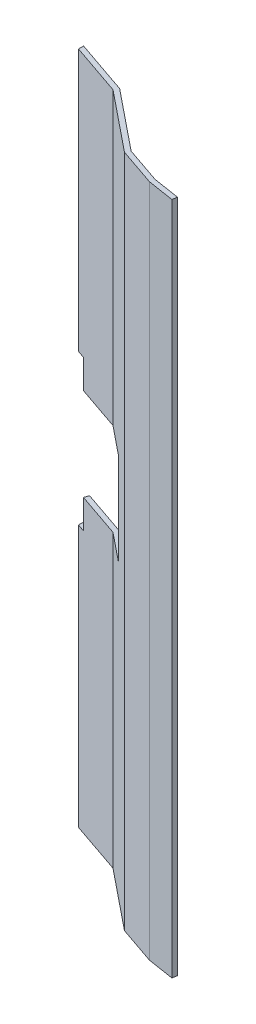
from build123d import *

# Parameters (mm, degrees)
BOSS_EXTRUDE2_DEPTH     = 222.25
SKETCH4_W               = 3.175
SKETCH4_H               = 9.525
SKETCH4_W_2             = 11.35728502
SKETCH4_H_2             = 30.48
CUT_EXTRUDE2_DEPTH      = 20.034637206
CUT_EXTRUDE2_DEPTH_BACK = 28.684375793


with BuildPart() as part:
    # Sketch3 → Boss-Extrude2 (new body)
    with BuildSketch(Plane(origin=(0, 0, 0), x_dir=(1, 0, 0), z_dir=(0, 1, 0))):
        Polygon((-37.062566366, 21.904788086), (-19.755538483, 15.964920897), (0, 0), (12.541749156, -4.304397313), (21.323689681, -5.686287551), (21.57426256, -4.093891817), (12.792322036, -2.712001578), (0.780092903, 1.410661549), (-18.975445581, 17.375582446), (-37.062566366, 23.583181811), align=None)
    extrude(amount=BOSS_EXTRUDE2_DEPTH)

    # Sketch4 → Cut-Extrude2 (cut, two sides)
    with BuildSketch(Plane(origin=(3.335400558, 0, -9.718377301), x_dir=(-0.945844814, 0, -0.324619144), z_dir=(0.324619144, 0, -0.945844814))) as cut_extrude2_sk:
        with Locations((41.123488466, 131.1275)):
            Rectangle(SKETCH4_W, SKETCH4_H)
        Polygon((42.710988466, 95.885), (42.710988466, 126.365), (39.535988466, 126.365), (23.588273486, 126.365), (23.588273486, 95.885), (39.535988466, 95.885), align=None)
        with Locations((41.123488466, 91.1225)):
            Rectangle(SKETCH4_W, SKETCH4_H)
        with Locations((17.909630976, 111.125)):
            Rectangle(SKETCH4_W_2, SKETCH4_H_2)
    extrude(amount=CUT_EXTRUDE2_DEPTH, mode=Mode.SUBTRACT)
    extrude(cut_extrude2_sk.sketch, amount=-CUT_EXTRUDE2_DEPTH_BACK, mode=Mode.SUBTRACT)


solid = part.part
